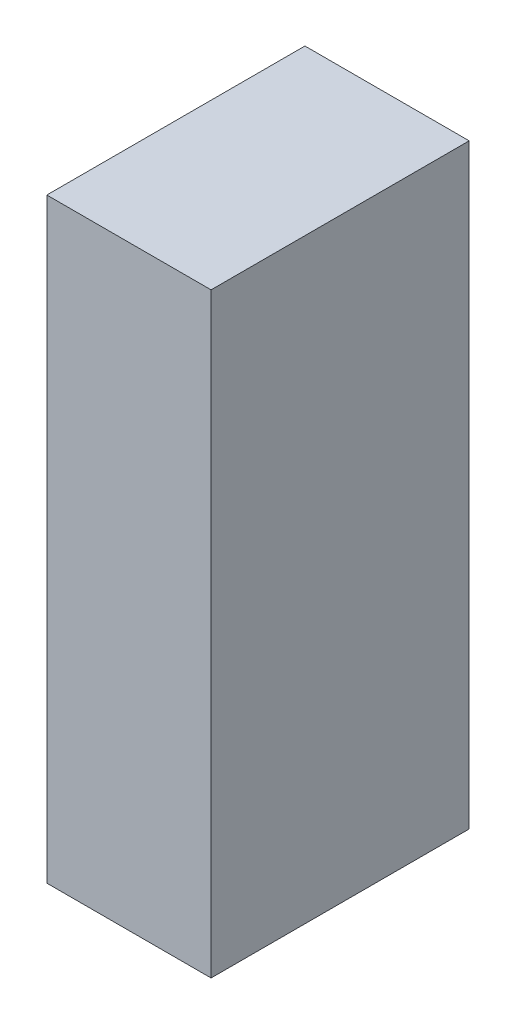
from build123d import *

# Parameters (mm, degrees)
SKETCH1_W           = 35
SKETCH1_H           = 55
BOSS_EXTRUDE1_DEPTH = 127


with BuildPart() as part:
    # Sketch1 → Boss-Extrude1 (new body)
    with BuildSketch(Plane(origin=(0, 0, 0), x_dir=(1, 0, 0), z_dir=(0, 1, 0))):
        Rectangle(SKETCH1_W, SKETCH1_H)
    extrude(amount=BOSS_EXTRUDE1_DEPTH)


solid = part.part
